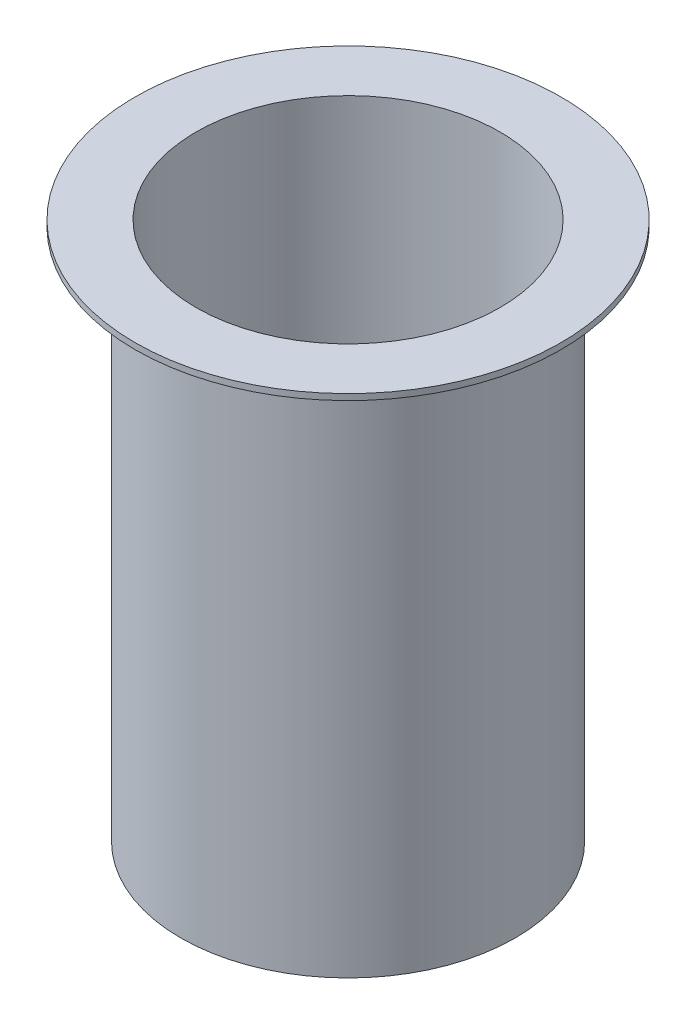
from build123d import *

# Parameters (mm, degrees)
CROQUIS1_R              = 55
CROQUIS1_R_2            = 50
SALIENTE_EXTRUIR1_DEPTH = 177
CROQUIS2_R              = 70
CROQUIS2_R_2            = 50
SALIENTE_EXTRUIR2_DEPTH = 2


with BuildPart() as part:
    # Croquis1 → Saliente-Extruir1 (new body)
    with BuildSketch(Plane(origin=(0, 0, 0), x_dir=(1, 0, 0), z_dir=(0, 1, 0))):
        Circle(CROQUIS1_R)
        Circle(CROQUIS1_R_2, mode=Mode.SUBTRACT)
    extrude(amount=-SALIENTE_EXTRUIR1_DEPTH)

    # Croquis2 → Saliente-Extruir2 (add)
    with BuildSketch(Plane(origin=(0, 0, 0), x_dir=(1, 0, 0), z_dir=(0, 1, 0))):
        Circle(CROQUIS2_R)
        Circle(CROQUIS2_R_2, mode=Mode.SUBTRACT)
    extrude(amount=-SALIENTE_EXTRUIR2_DEPTH)


solid = part.part
